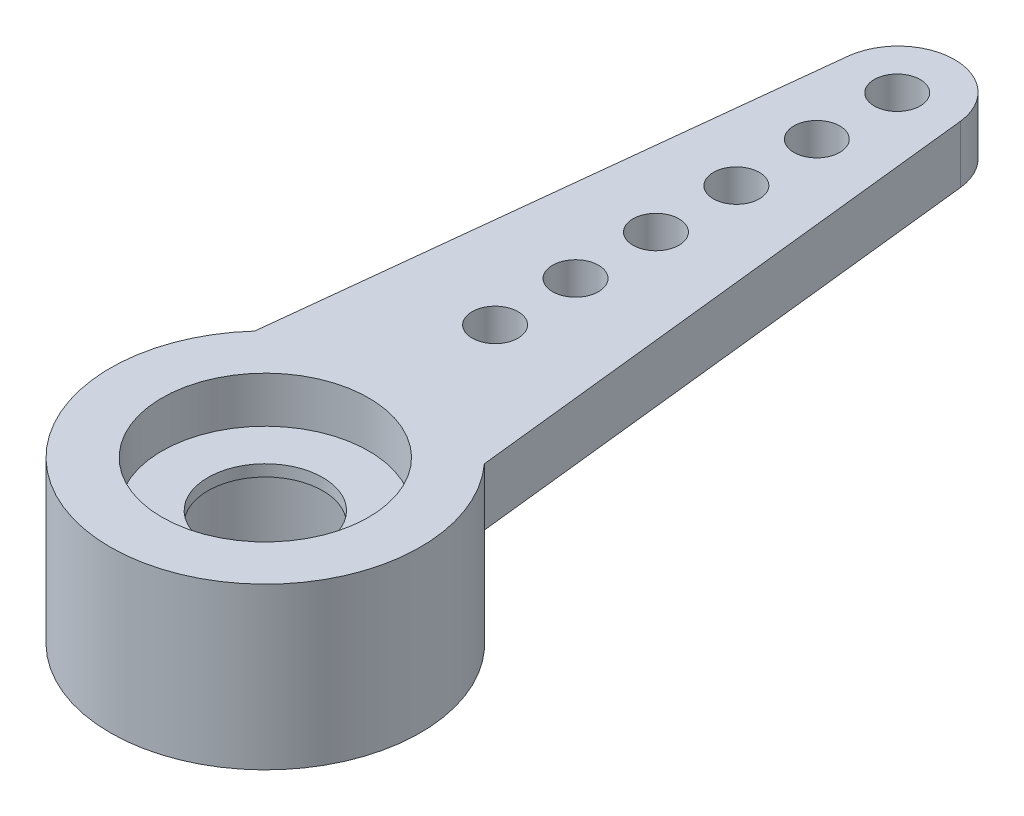
from build123d import *

# Parameters (mm, degrees)
SKETCH1_R           = 3.429
SKETCH1_R_2         = 2.286
BOSS_EXTRUDE1_DEPTH = 3.556
BOSS_EXTRUDE2_START = -1.27
BOSS_EXTRUDE2_DEPTH = 1.27
BOSS_EXTRUDE3_START = -1.27
SKETCH2_3_R         = 2.286
SKETCH2_3_R_2       = 1.27
BOSS_EXTRUDE3_DEPTH = 0.254
SKETCH3_R           = 0.508
CUT_EXTRUDE1_DEPTH  = 17.020635974
LPATTERN1_COUNT     = 6
LPATTERN1_PITCH     = 1.778


with BuildPart() as part:
    # Sketch1 → Boss-Extrude1 (new body)
    with BuildSketch(Plane(origin=(0, 0, 0), x_dir=(1, 0, 0), z_dir=(0, 1, 0))):
        Circle(SKETCH1_R)
        Circle(SKETCH1_R_2, mode=Mode.SUBTRACT)
    extrude(amount=BOSS_EXTRUDE1_DEPTH)

    # Sketch2 → Boss-Extrude2 (add)
    with BuildSketch(Plane(origin=(0, 3.556, 0), x_dir=(1, 0, 0), z_dir=(0, 1, 0)).offset(BOSS_EXTRUDE2_START)):
        with BuildLine():
            ThreePointArc((-2.54, 2.303571358), (0, 3.429), (2.54, 2.303571358))
            Line((2.54, 2.303571358), (1.244511661, 14.124427226))
            ThreePointArc((1.244511661, 14.124427226), (0, 15.24), (-1.244511661, 14.124427226))
            Line((-1.244511661, 14.124427226), (-2.54, 2.303571358))
        make_face()
    extrude(amount=BOSS_EXTRUDE2_DEPTH)

    # Sketch2_3 → Boss-Extrude3 (add)
    with BuildSketch(Plane(origin=(0, 3.556, 0), x_dir=(1, 0, 0), z_dir=(0, 1, 0)).offset(BOSS_EXTRUDE3_START)):
        Circle(SKETCH2_3_R)
        Circle(SKETCH2_3_R_2, mode=Mode.SUBTRACT)
    extrude(amount=BOSS_EXTRUDE3_DEPTH)

    # Sketch3 → Cut-Extrude1 (cut, through all)
    with BuildSketch(Plane(origin=(0, 3.556, 0), x_dir=(1, 0, 0), z_dir=(0, 1, 0))):
        with Locations((0, 5.08)):
            Circle(SKETCH3_R)
    cut_extrude1 = extrude(amount=-CUT_EXTRUDE1_DEPTH, mode=Mode.SUBTRACT)

    # LPattern1: Cut-Extrude1 ×6
    with Locations(*[(0, 0, -i * LPATTERN1_PITCH) for i in range(1, LPATTERN1_COUNT)]):
        add(cut_extrude1, mode=Mode.SUBTRACT)


solid = part.part
